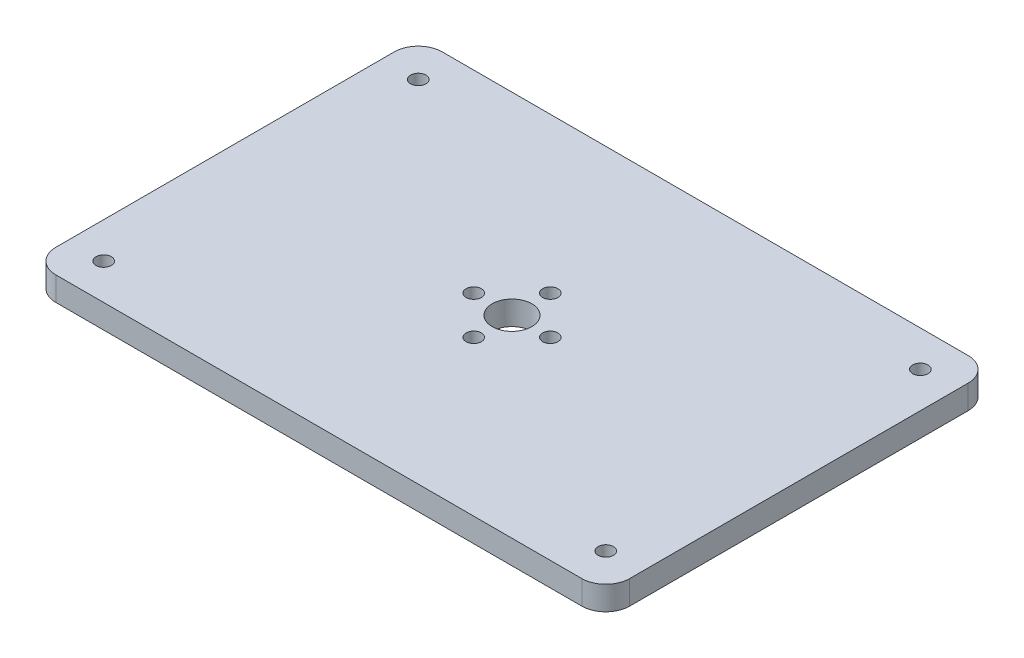
from build123d import *

# Parameters (mm, degrees)
SKETCH1_W           = 120
SKETCH1_H           = 80.79
SKETCH1_R           = 1.6
SKETCH1_R_2         = 4.15
BOSS_EXTRUDE1_DEPTH = 5
SKETCH2_R           = 1.6
CUT_EXTRUDE1_DEPTH  = 6
FILLET1_R           = 5


with BuildPart() as part:
    # Sketch1 → Boss-Extrude1 (new body)
    with BuildSketch(Plane(origin=(0, 0, 0), x_dir=(1, 0, 0), z_dir=(0, 1, 0))):
        with Locations((60, 40.395)):
            Rectangle(SKETCH1_W, SKETCH1_H)
        with Locations((52, 40.395)):
            Circle(SKETCH1_R, mode=Mode.SUBTRACT)
        with Locations((60, 48.395)):
            Circle(SKETCH1_R, mode=Mode.SUBTRACT)
        with Locations((68, 40.395)):
            Circle(SKETCH1_R, mode=Mode.SUBTRACT)
        with Locations((60, 32.395)):
            Circle(SKETCH1_R, mode=Mode.SUBTRACT)
        with Locations((60, 40.395)):
            Circle(SKETCH1_R_2, mode=Mode.SUBTRACT)
    extrude(amount=BOSS_EXTRUDE1_DEPTH)

    # Sketch2 → Cut-Extrude1 (cut, through all)
    with BuildSketch(Plane(origin=(0, 5, 0), x_dir=(1, 0, 0), z_dir=(0, 1, 0))):
        with Locations((7.5, 7.5)):
            Circle(SKETCH2_R)
        with Locations((7.5, 73.29)):
            Circle(SKETCH2_R)
        with Locations((112.5, 7.5)):
            Circle(SKETCH2_R)
        with Locations((112.5, 73.29)):
            Circle(SKETCH2_R)
    extrude(amount=-CUT_EXTRUDE1_DEPTH, mode=Mode.SUBTRACT)

    # Fillet1
    fillet1_edges = [part.edges().sort_by_distance(p)[0] for p in [
        (0, 2.5, -80.79),
        (120, 2.5, -80.79),
        (120, 2.5, 0),
        (0, 2.5, 0),
    ]]
    fillet(fillet1_edges, radius=FILLET1_R)


solid = part.part
